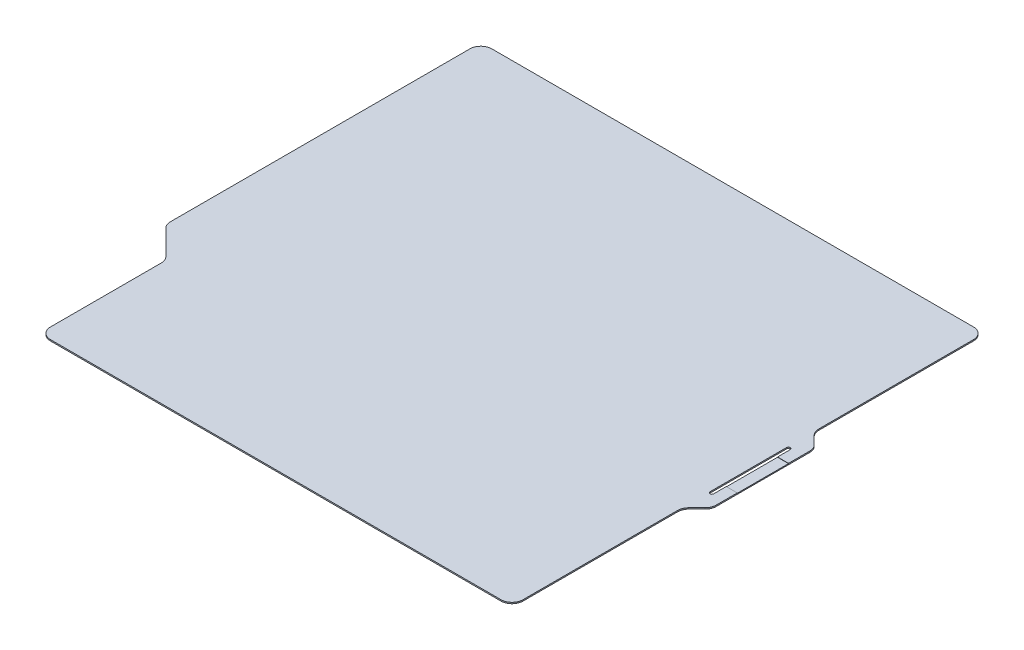
from build123d import *

# Parameters (mm, degrees)
BOSS_EXTRUDE1_DEPTH = 0.69
CUT_EXTRUDE1_DEPTH  = 1.69
SKETCH3_W           = 6
SKETCH3_H           = 28
CUT_EXTRUDE2_DEPTH  = 0.14
FILLET1_R           = 6


with BuildPart() as part:
    # Sketch1 → Boss-Extrude1 (new body)
    with BuildSketch(Plane(origin=(0, 0, 0), x_dir=(1, 0, 0), z_dir=(0, 1, 0))):
        Polygon((-146, 129), (-146, -43), (-129, -60), (-129, -129), (129, -129), (129, -36), (137, -28), (137, 28), (129, 36), (129, 129), align=None)
    extrude(amount=BOSS_EXTRUDE1_DEPTH)

    # Sketch2 → Cut-Extrude1 (cut, through all)
    with BuildSketch(Plane(origin=(0, 0.69, 0), x_dir=(1, 0, 0), z_dir=(0, 1, 0))):
        with BuildLine():
            Line((131, 20.875), (131, -20.875))
            ThreePointArc((131, -20.875), (130, -21.875), (129, -20.875))
            Line((129, -20.875), (129, 20.875))
            ThreePointArc((129, 20.875), (130, 21.875), (131, 20.875))
        make_face()
    extrude(amount=-CUT_EXTRUDE1_DEPTH, mode=Mode.SUBTRACT)

    # Sketch3 → Cut-Extrude2 (cut)
    with BuildSketch(Plane(origin=(0, 0.69, 0), x_dir=(1, 0, 0), z_dir=(0, 1, 0))):
        with Locations((134, 0)):
            Rectangle(SKETCH3_W, SKETCH3_H)
    extrude(amount=-CUT_EXTRUDE2_DEPTH, mode=Mode.SUBTRACT)

    # Fillet1
    fillet1_edges = [part.edges().sort_by_distance(p)[0] for p in [
        (129, 0.345, 36),
        (129, 0.345, 129),
        (-129, 0.345, 129),
        (-129, 0.345, 60),
        (-146, 0.345, 43),
        (-146, 0.345, -129),
        (129, 0.345, -129),
        (129, 0.345, -36),
        (137, 0.345, -28),
        (137, 0.345, 28),
    ]]
    fillet(fillet1_edges, radius=FILLET1_R)


solid = part.part
